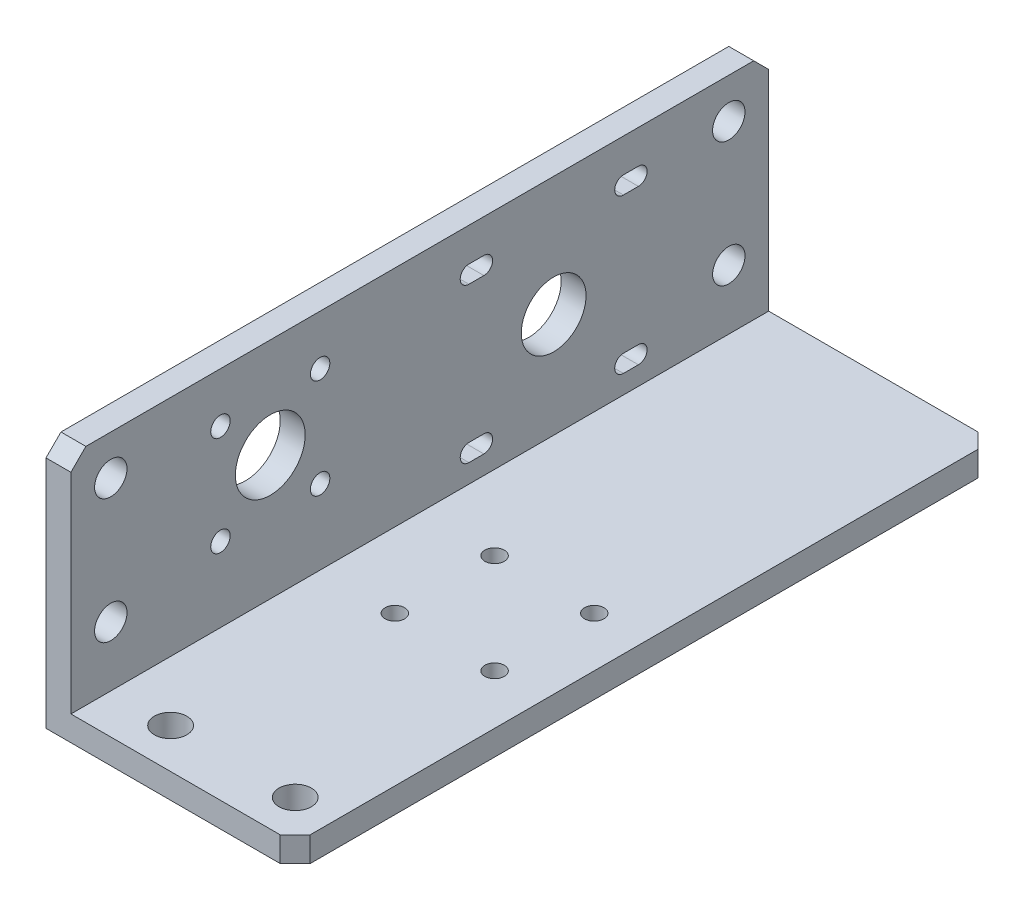
from build123d import *

# Parameters (mm, degrees)
ESTRUSIONE_ESTRUSIONE1_DEPTH = 140
FORO_6_5_6_5_1_D             = 6.5
FORO_6_5_6_5_2_AT_2_COUNT    = 2
FORO_6_5_6_5_2_AT_2_PITCH    = 25
TAGLIO_ESTRUSIONE2_REACH     = 52
SCHIZZO9_R                   = 7
TAGLIO_ESTRUSIONE4_REACH     = 52
SCHIZZO11_R                  = 6.5
SMUSSO1_SIZE                 = 3
M3_5_CLEARANCE_HOLE1_D       = 3.9
M3_5_CLEARANCE_HOLE2_D       = 3.9


with BuildPart() as part:
    # Schizzo1 → Estrusione-Estrusione1 (new body)
    with BuildSketch(Plane.XY):
        Polygon((0, 0), (0, 50), (5, 50), (5, 5), (50, 5), (50, 0), align=None)
    extrude(amount=ESTRUSIONE_ESTRUSIONE1_DEPTH)

    # Foro Ø6.5 (6.5)-1 (through all)
    with Locations(Plane(origin=(0, 0, 0), x_dir=(-1, 0, 0), z_dir=(0, -1, 0))):
        with Locations((-17, -132), (-42, -132)):
            Hole(FORO_6_5_6_5_1_D / 2)

    # Schizzo6 → Foro Ø6.5 (6.5)-2 (revolve, cut)
    with BuildSketch(Plane(origin=(0, 42, 132), x_dir=(0, 0, 1), z_dir=(0, 1, 0))):
        Polygon((0, 0), (0, 6.952797012), (3.25, 5), (3.25, 0), align=None)
    foro_6_5_6_5_2 = revolve(axis=Axis((-6.35, 42, 132), (1, 0, 0)), mode=Mode.SUBTRACT)

    # Foro Ø6.5 (6.5)-2 at 2: Foro Ø6.5 (6.5)-2 ×2
    with Locations(*[(0, -i * FORO_6_5_6_5_2_AT_2_PITCH, 0) for i in range(1, FORO_6_5_6_5_2_AT_2_COUNT)]):
        add(foro_6_5_6_5_2, mode=Mode.SUBTRACT)

    # Specchia1: Foro Ø6.5 (6.5)-2 across plane
    add(foro_6_5_6_5_2.mirror(Plane.XY.offset(70)), mode=Mode.SUBTRACT)

    # Specchia1 copy 1 sketch → Specchia1 copy 1 (revolve, cut)
    with BuildSketch(Plane(origin=(0, 17, 8), x_dir=(0, 0, -1), z_dir=(0, 1, 0))):
        Polygon((0, 0), (0, -6.952797012), (3.25, -5), (3.25, 0), align=None)
    revolve(axis=Axis((-6.35, 17, 8), (-1, 0, 0)), mode=Mode.SUBTRACT)

    # Schizzo9 → Taglio-Estrusione2 (cut, up to next)
    with BuildSketch(Plane.ZY, mode=Mode.PRIVATE) as taglio_estrusione2_sk1:
        with Locations((100, 30)):
            Circle(SCHIZZO9_R)
    taglio_estrusione2_tool1 = extrude(taglio_estrusione2_sk1.sketch, amount=-TAGLIO_ESTRUSIONE2_REACH, mode=Mode.PRIVATE) & part.part
    add(taglio_estrusione2_tool1.solids().sort_by_distance((0, 30, 100))[0], mode=Mode.SUBTRACT)

    # Schizzo11 → Taglio-Estrusione4 (cut, up to next)
    with BuildSketch(Plane.ZY, mode=Mode.PRIVATE) as taglio_estrusione4_sk1:
        with Locations((43.140524097, 26)):
            Circle(SCHIZZO11_R)
    taglio_estrusione4_tool1 = extrude(taglio_estrusione4_sk1.sketch, amount=-TAGLIO_ESTRUSIONE4_REACH, mode=Mode.PRIVATE) & part.part
    add(taglio_estrusione4_tool1.solids().sort_by_distance((0, 26, 43.140524))[0], mode=Mode.SUBTRACT)
    # Schizzo11 → Taglio-Estrusione4 (cut, up to next)
    with BuildSketch(Plane.ZY, mode=Mode.PRIVATE) as taglio_estrusione4_sk2:
        with BuildLine():
            Line((60.140524097, 39.75), (57.140524097, 39.75))
            ThreePointArc((57.140524097, 39.75), (55.390524097, 41.5), (57.140524097, 43.25))
            Line((57.140524097, 43.25), (60.140524097, 43.25))
            ThreePointArc((60.140524097, 43.25), (61.890524097, 41.5), (60.140524097, 39.75))
        make_face()
    taglio_estrusione4_tool2 = extrude(taglio_estrusione4_sk2.sketch, amount=-TAGLIO_ESTRUSIONE4_REACH, mode=Mode.PRIVATE) & part.part
    add(taglio_estrusione4_tool2.solids().sort_by_distance((0, 41.5, 58.640524))[0], mode=Mode.SUBTRACT)
    # Schizzo11 → Taglio-Estrusione4 (cut, up to next)
    with BuildSketch(Plane.ZY, mode=Mode.PRIVATE) as taglio_estrusione4_sk3:
        with BuildLine():
            Line((60.140524097, 12.25), (57.140524097, 12.25))
            ThreePointArc((57.140524097, 12.25), (55.390524097, 10.5), (57.140524097, 8.75))
            Line((57.140524097, 8.75), (60.140524097, 8.75))
            ThreePointArc((60.140524097, 8.75), (61.890524097, 10.5), (60.140524097, 12.25))
        make_face()
    taglio_estrusione4_tool3 = extrude(taglio_estrusione4_sk3.sketch, amount=-TAGLIO_ESTRUSIONE4_REACH, mode=Mode.PRIVATE) & part.part
    add(taglio_estrusione4_tool3.solids().sort_by_distance((0, 10.5, 58.640524))[0], mode=Mode.SUBTRACT)
    # Schizzo11 → Taglio-Estrusione4 (cut, up to next)
    with BuildSketch(Plane.ZY, mode=Mode.PRIVATE) as taglio_estrusione4_sk4:
        with BuildLine():
            Line((26.140524097, 12.25), (29.140524097, 12.25))
            ThreePointArc((29.140524097, 12.25), (30.890524097, 10.5), (29.140524097, 8.75))
            Line((29.140524097, 8.75), (26.140524097, 8.75))
            ThreePointArc((26.140524097, 8.75), (24.390524097, 10.5), (26.140524097, 12.25))
        make_face()
    taglio_estrusione4_tool4 = extrude(taglio_estrusione4_sk4.sketch, amount=-TAGLIO_ESTRUSIONE4_REACH, mode=Mode.PRIVATE) & part.part
    add(taglio_estrusione4_tool4.solids().sort_by_distance((0, 10.5, 27.640524))[0], mode=Mode.SUBTRACT)
    # Schizzo11 → Taglio-Estrusione4 (cut, up to next)
    with BuildSketch(Plane.ZY, mode=Mode.PRIVATE) as taglio_estrusione4_sk5:
        with BuildLine():
            Line((26.140524097, 39.75), (29.140524097, 39.75))
            ThreePointArc((29.140524097, 39.75), (30.890524097, 41.5), (29.140524097, 43.25))
            Line((29.140524097, 43.25), (26.140524097, 43.25))
            ThreePointArc((26.140524097, 43.25), (24.390524097, 41.5), (26.140524097, 39.75))
        make_face()
    taglio_estrusione4_tool5 = extrude(taglio_estrusione4_sk5.sketch, amount=-TAGLIO_ESTRUSIONE4_REACH, mode=Mode.PRIVATE) & part.part
    add(taglio_estrusione4_tool5.solids().sort_by_distance((0, 41.5, 27.640524))[0], mode=Mode.SUBTRACT)

    # Smusso1
    smusso1_edges = [part.edges().sort_by_distance(p)[0] for p in [
        (2.5, 50, 140),
        (2.5, 50, 0),
        (50, 2.5, 140),
        (50, 2.5, 0),
    ]]
    chamfer(smusso1_edges, length=SMUSSO1_SIZE)

    # M3.5 Clearance Hole1 (through all)
    with Locations(Plane(origin=(0, 40, 90), x_dir=(0, 0, -1), z_dir=(-1, 0, 0))):
        with Locations((0, 0), (-20, 0), (-20, 20), (0, 20)):
            Hole(M3_5_CLEARANCE_HOLE1_D / 2)

    # M3.5 Clearance Hole2 (through all)
    with Locations(Plane(origin=(20, 0, 90), x_dir=(-1, 0, 0), z_dir=(0, -1, 0))):
        with Locations((0, 0), (-20, 0), (-20, 20), (0, 20)):
            Hole(M3_5_CLEARANCE_HOLE2_D / 2)


solid = part.part
